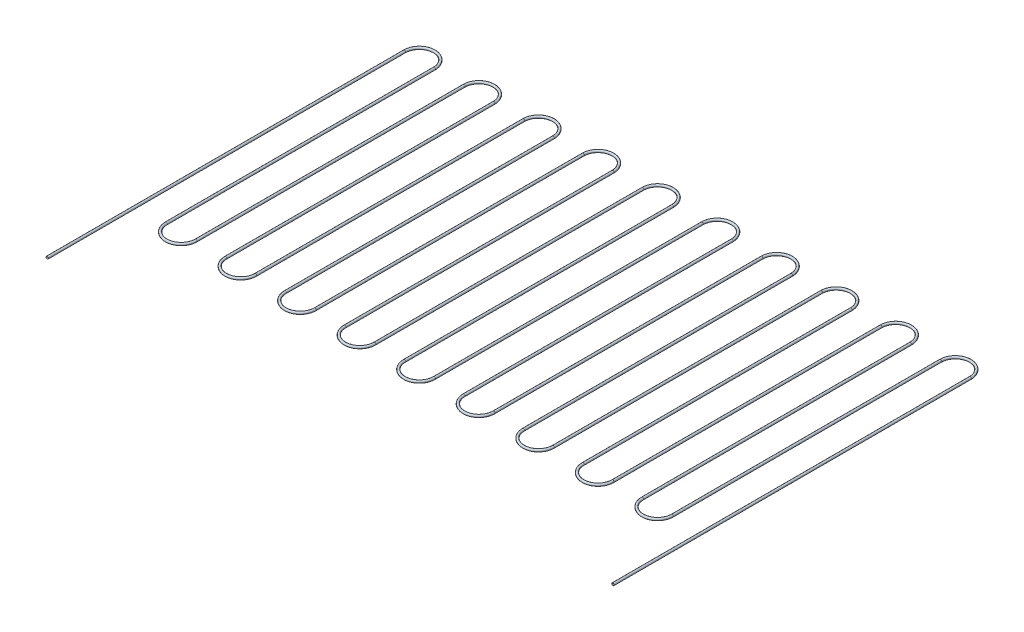
from build123d import *

# Parameters (mm, degrees)
SWEEP_THIN1_PROFILE_R   = 3.96875
SWEEP_THIN1_PROFILE_R_2 = 3.61875


with BuildPart() as part:
    # Sweep-Thin1: sweep along a path in Sketch4
    with BuildLine(Plane(origin=(0, 0, 0), x_dir=(1, 0, 0), z_dir=(0, 1, 0))) as sweep_thin1_path:
        Line((-950, -750), (-950, -450))
        Line((-950, -450), (-950, 450))
        ThreePointArc((-950, 450), (-900, 500), (-850, 450))
        Line((-850, 450), (-850, -450))
        ThreePointArc((-850, -450), (-800, -500), (-750, -450))
        Line((-750, -450), (-750, 450))
        ThreePointArc((-750, 450), (-700, 500), (-650, 450))
        Line((-650, 450), (-650, -450))
        ThreePointArc((-650, -450), (-600, -500), (-550, -450))
        Line((-550, -450), (-550, 450))
        ThreePointArc((-550, 450), (-500, 500), (-450, 450))
        Line((-450, 450), (-450, -450))
        ThreePointArc((-450, -450), (-400, -500), (-350, -450))
        Line((-350, -450), (-350, 450))
        ThreePointArc((-350, 450), (-300, 500), (-250, 450))
        Line((-250, 450), (-250, -450))
        ThreePointArc((-250, -450), (-200, -500), (-150, -450))
        Line((-150, -450), (-150, 450))
        ThreePointArc((-150, 450), (-100, 500), (-50, 450))
        Line((-50, 450), (-50, -450))
        ThreePointArc((-50, -450), (0, -500), (50, -450))
        Line((50, -450), (50, 450))
        ThreePointArc((50, 450), (100, 500), (150, 450))
        Line((150, 450), (150, -450))
        ThreePointArc((150, -450), (200, -500), (250, -450))
        Line((250, -450), (250, 450))
        ThreePointArc((250, 450), (300, 500), (350, 450))
        Line((350, 450), (350, -450))
        ThreePointArc((350, -450), (400, -500), (450, -450))
        Line((450, -450), (450, 450))
        ThreePointArc((450, 450), (500, 500), (550, 450))
        Line((550, 450), (550, -450))
        ThreePointArc((550, -450), (600, -500), (650, -450))
        Line((650, -450), (650, 450))
        ThreePointArc((650, 450), (700, 500), (750, 450))
        Line((750, 450), (750, -450))
        ThreePointArc((750, -450), (800, -500), (850, -450))
        Line((850, -450), (850, 450))
        ThreePointArc((850, 450), (900, 500), (950, 450))
        Line((950, 450), (950, -450))
        Line((950, -450), (950, -750))
    # Sweep-Thin1 profile (on start of the path) → Sweep-Thin1 (sweep)
    with BuildSketch(Plane(origin=(-950, 0, 750), x_dir=(-1, 0, 0), z_dir=(0, 0, -1))):
        Circle(SWEEP_THIN1_PROFILE_R)
        Circle(SWEEP_THIN1_PROFILE_R_2, mode=Mode.SUBTRACT)
    sweep(path=sweep_thin1_path.line)


solid = part.part
